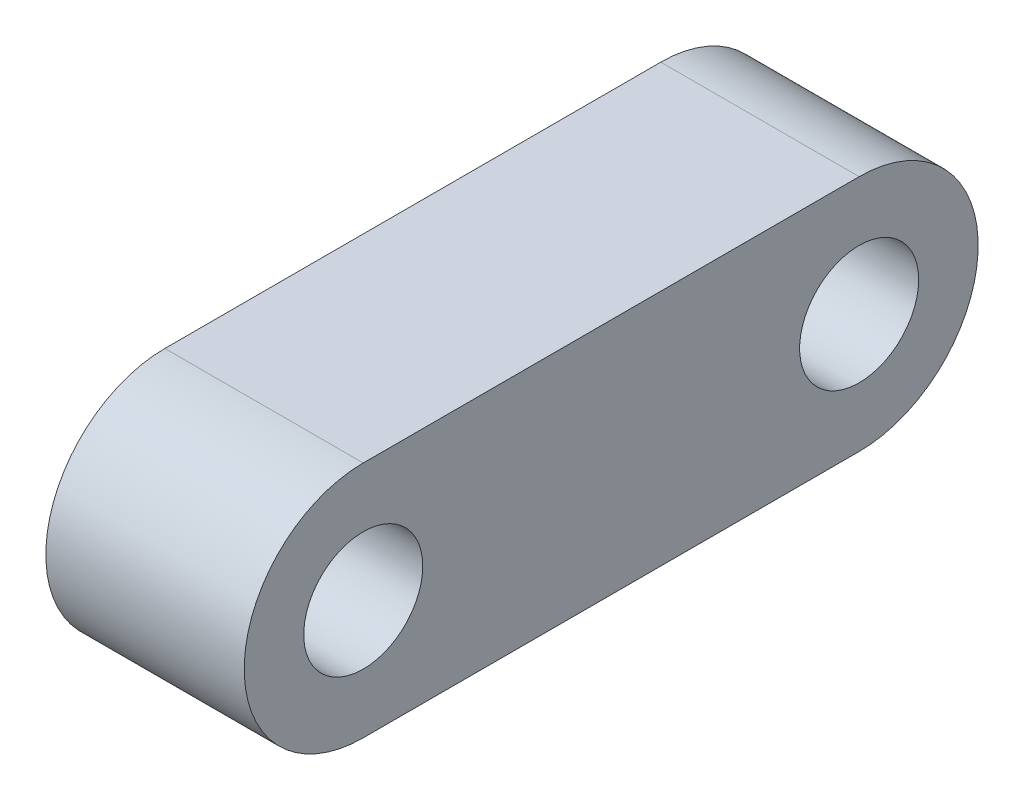
from build123d import *

# Parameters (mm, degrees)
SKETCH_1_R      = 1.5
EXTRUDE_1_DEPTH = 2.5


with BuildPart() as part:
    # 草图1 → 凸台-拉伸1 (new body, symmetric)
    with BuildSketch(Plane(origin=(0, 0, 0), x_dir=(0, 0, -1), z_dir=(1, 0, 0))):
        with BuildLine():
            Line((-6.25, 3), (6.25, 3))
            ThreePointArc((6.25, 3), (9.25, 0), (6.25, -3))
            Line((6.25, -3), (-6.25, -3))
            ThreePointArc((-6.25, -3), (-9.25, 0), (-6.25, 3))
        make_face()
        with Locations((6.25, 0)):
            Circle(SKETCH_1_R, mode=Mode.SUBTRACT)
        with Locations((-6.25, 0)):
            Circle(SKETCH_1_R, mode=Mode.SUBTRACT)
    extrude(amount=EXTRUDE_1_DEPTH, both=True)


solid = part.part
